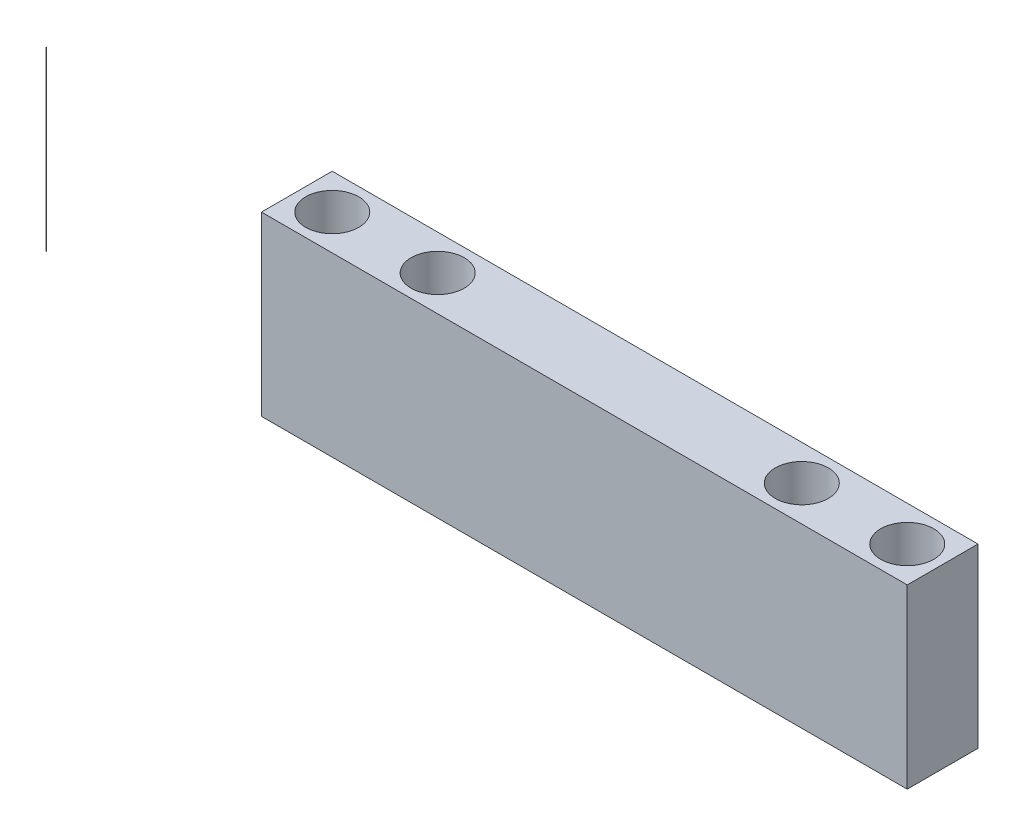
from build123d import *

# Parameters (mm, degrees)
SKETCH1_R             = 0.129035646
BOSS_EXTRUDE1_DEPTH   = 127
SKETCH1_W             = 463.55
SKETCH1_H             = 50.8
SKETCH1_R_2           = 19.05
BOSS_EXTRUDE1_2_DEPTH = 127


with BuildPart() as part:
    # Sketch1 → Boss-Extrude1 (new body)
    with BuildSketch(Plane(origin=(0, 0, 0), x_dir=(1, 0, 0), z_dir=(0, 1, 0))):
        with Locations((-411.662010213, 0)):
            Circle(SKETCH1_R)
    extrude(amount=BOSS_EXTRUDE1_DEPTH)


with BuildPart() as body_2:
    # Sketch1 → Boss-Extrude1 2 (new body)
    with BuildSketch(Plane(origin=(0, 0, 0), x_dir=(1, 0, 0), z_dir=(0, 1, 0))):
        Rectangle(SKETCH1_W, SKETCH1_H)
        with Locations((206.375, 0)):
            Circle(SKETCH1_R_2, mode=Mode.SUBTRACT)
        with Locations((-206.375, 0)):
            Circle(SKETCH1_R_2, mode=Mode.SUBTRACT)
        with Locations((130.683, 0)):
            Circle(SKETCH1_R_2, mode=Mode.SUBTRACT)
        with Locations((-130.683, 0)):
            Circle(SKETCH1_R_2, mode=Mode.SUBTRACT)
    extrude(amount=BOSS_EXTRUDE1_2_DEPTH)


solid = Compound([part.part, body_2.part])
